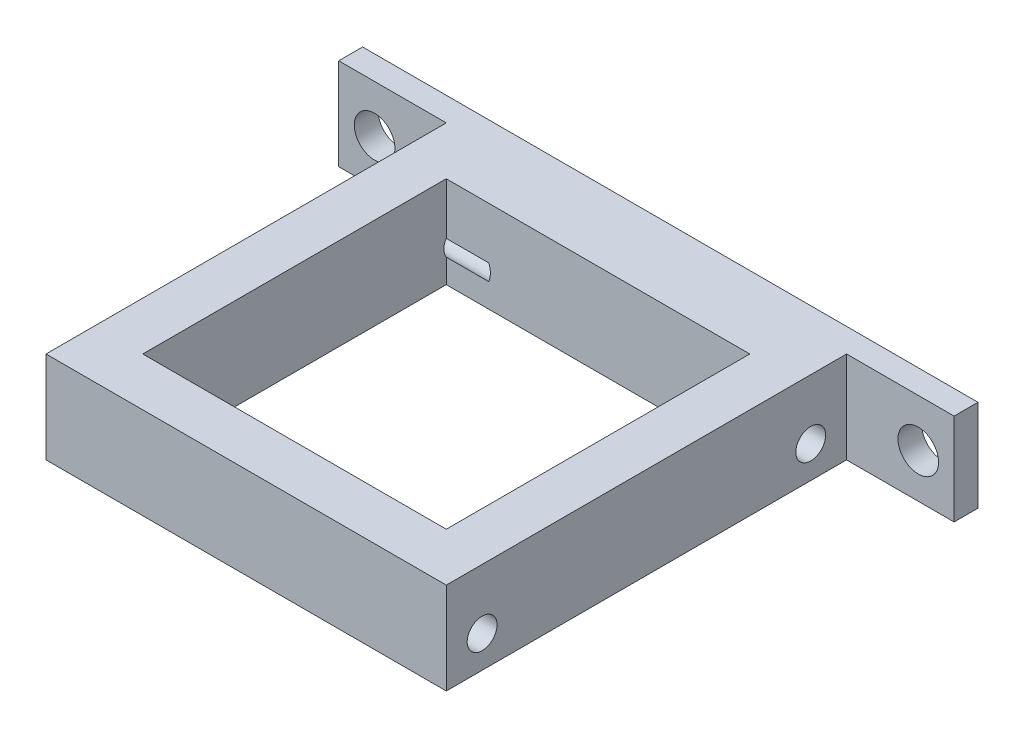
from build123d import *

# Parameters (mm, degrees)
SKETCH1_W                      = 33.5
SKETCH1_H                      = 33.5
BOSS_EXTRUDE1_DEPTH            = 70
M3X0_5_TAPPED_HOLE1_D          = 2.5
M3X0_5_TAPPED_HOLE1_DEPTH      = 7.62
M3X0_5_TAPPED_HOLE1_TIP        = 0.751075774
M3X0_5_TAPPED_HOLE2_D          = 2.5
M3X0_5_TAPPED_HOLE2_DEPTH      = 7.62
M3X0_5_TAPPED_HOLE2_TIP        = 0.751075774
SKETCH7_W                      = 6
SKETCH7_H                      = 50
BOSS_EXTRUDE2_DEPTH            = 3
SKETCH8_W                      = 6
SKETCH8_H                      = 50
BOSS_EXTRUDE3_DEPTH            = 3
SKETCH10_W                     = 1.7
SKETCH10_H                     = 33.5
M3_CLEARANCE_HOLE1_AT_2_COUNT  = 2
M3_CLEARANCE_HOLE1_AT_2_PITCH  = 25
M3_CLEARANCE_HOLE1_AT_3_COUNT  = 2
M3_CLEARANCE_HOLE1_AT_3_PITCH  = 39.5
M3_CLEARANCE_HOLE1_AT_4_COUNT  = 2
M3_CLEARANCE_HOLE1_AT_4_PITCH  = 46.746657635
SKETCH12_W                     = 33.5
SKETCH12_H                     = 45
CUT_EXTRUDE2_DEPTH             = 32.5
M3X0_5_TAPPED_HOLE3_AT_2_COUNT = 2
M3X0_5_TAPPED_HOLE3_AT_2_PITCH = 27.5
SKETCH16_W                     = 45.5
SKETCH16_H                     = 59.85996371
CUT_EXTRUDE3_DEPTH             = 34.5
SKETCH17_W                     = 51.5
SKETCH17_H                     = 11
BOSS_EXTRUDE4_DEPTH            = 2
SKETCH22_W                     = 51.5
SKETCH22_H                     = 3.322905466
CUT_EXTRUDE5_DEPTH             = 36.5
M3_CLEARANCE_HOLE3_D           = 3.4
SKETCH24_W                     = 25.4
SKETCH24_H                     = 25.4
CUT_EXTRUDE6_DEPTH             = 8.677094534


with BuildPart() as part:
    # Sketch1 → Boss-Extrude1 (new body)
    with BuildSketch(Plane(origin=(0, 0, 0), x_dir=(1, 0, 0), z_dir=(0, 1, 0))):
        Rectangle(SKETCH1_W, SKETCH1_H)
    extrude(amount=BOSS_EXTRUDE1_DEPTH)

    # M3x0.5 Tapped Hole1
    with Locations(Plane(origin=(13.75, 70, 13.75), x_dir=(0, 0, 1), z_dir=(0, 1, 0))):
        with Locations((0, 0), (-27.5, -27.5)):
            Hole(M3X0_5_TAPPED_HOLE1_D / 2, depth=M3X0_5_TAPPED_HOLE1_DEPTH)
            with Locations((0, 0, -(M3X0_5_TAPPED_HOLE1_DEPTH + M3X0_5_TAPPED_HOLE1_TIP / 2))):  # 118° drill point
                Cone(0, M3X0_5_TAPPED_HOLE1_D / 2, M3X0_5_TAPPED_HOLE1_TIP, mode=Mode.SUBTRACT)

    # M3x0.5 Tapped Hole2
    with Locations(Plane(origin=(16.75, 6, 13.75), x_dir=(0, 0, 1), z_dir=(1, 0, 0))):
        with Locations((0, 0), (-27.5, 0)):
            Hole(M3X0_5_TAPPED_HOLE2_D / 2, depth=M3X0_5_TAPPED_HOLE2_DEPTH)
            with Locations((0, 0, -(M3X0_5_TAPPED_HOLE2_DEPTH + M3X0_5_TAPPED_HOLE2_TIP / 2))):  # 118° drill point
                Cone(0, M3X0_5_TAPPED_HOLE2_D / 2, M3X0_5_TAPPED_HOLE2_TIP, mode=Mode.SUBTRACT)

    # Sketch12 → Cut-Extrude2 (cut)
    with BuildSketch(Plane.XY.offset(16.75)):
        with Locations((0, 35.5)):
            Rectangle(SKETCH12_W, SKETCH12_H)
    extrude(amount=-CUT_EXTRUDE2_DEPTH, mode=Mode.SUBTRACT)

    # Sketch13 → M3x0.5 Tapped Hole3 (revolve, cut)
    with BuildSketch(Plane(origin=(-16.75, 6, -13.75), x_dir=(0, 0, 1), z_dir=(0, 1, 0))):
        Polygon((0, 0), (0, 8.371075774), (1.25, 7.62), (1.25, 0), align=None)
    m3x0_5_tapped_hole3 = revolve(axis=Axis((-23.1, 6, -13.75), (1, 0, 0)), mode=Mode.SUBTRACT)

    # M3x0.5 Tapped Hole3 at 2: M3x0.5 Tapped Hole3 ×2
    with Locations(*[(0, 0, i * M3X0_5_TAPPED_HOLE3_AT_2_PITCH) for i in range(1, M3X0_5_TAPPED_HOLE3_AT_2_COUNT)]):
        add(m3x0_5_tapped_hole3, mode=Mode.SUBTRACT)


with BuildPart() as body_2:
    # Sketch7 → Boss-Extrude2 (new body)
    with BuildSketch(Plane(origin=(0, 0, -16.75), x_dir=(-1, 0, 0), z_dir=(0, 0, -1))):
        with Locations((-19.75, 36)):
            Rectangle(SKETCH7_W, SKETCH7_H)
    extrude(amount=-BOSS_EXTRUDE2_DEPTH)

    # Sketch10 → M3 Clearance Hole1 (revolve, cut)
    with BuildSketch(Plane(origin=(19.75, 51, -16.75), x_dir=(0, 1, 0), z_dir=(1, 0, 0))):
        with Locations((0.85, 16.75)):
            Rectangle(SKETCH10_W, SKETCH10_H)
    m3_clearance_hole1 = revolve(axis=Axis((19.75, 51, -23.1), (0, 0, 1)), mode=Mode.SUBTRACT)

    # M3 Clearance Hole1 at 2: M3 Clearance Hole1 ×2
    with Locations(*[(0, -i * M3_CLEARANCE_HOLE1_AT_2_PITCH, 0) for i in range(1, M3_CLEARANCE_HOLE1_AT_2_COUNT)]):
        add(m3_clearance_hole1, mode=Mode.SUBTRACT)


with BuildPart() as body_3:
    # Sketch8 → Boss-Extrude3 (new body)
    with BuildSketch(Plane(origin=(0, 0, -16.75), x_dir=(-1, 0, 0), z_dir=(0, 0, -1))):
        with Locations((19.75, 36)):
            Rectangle(SKETCH8_W, SKETCH8_H)
    extrude(amount=-BOSS_EXTRUDE3_DEPTH)

    # M3 Clearance Hole1 at 3: M3 Clearance Hole1 ×2
    with Locations(*[(-i * M3_CLEARANCE_HOLE1_AT_3_PITCH, 0, 0) for i in range(1, M3_CLEARANCE_HOLE1_AT_3_COUNT)]):
        add(m3_clearance_hole1, mode=Mode.SUBTRACT)

    # M3 Clearance Hole1 at 4: M3 Clearance Hole1 ×2
    with Locations(*[Vector(-0.844980197, -0.534797593, 0) * (i * M3_CLEARANCE_HOLE1_AT_4_PITCH) for i in range(1, M3_CLEARANCE_HOLE1_AT_4_COUNT)]):
        add(m3_clearance_hole1, mode=Mode.SUBTRACT)


with BuildPart() as cut_extrude3_tool:
    # Sketch16 → Cut-Extrude3 (new body, through all)
    with BuildSketch(Plane.XY.offset(16.75)):
        with Locations((0, 40.929981855)):
            Rectangle(SKETCH16_W, SKETCH16_H)
    extrude(amount=-CUT_EXTRUDE3_DEPTH)


with BuildPart() as part_1:
    add(part.part)

    # Cut-Extrude3: cut by cut_extrude3_tool
    add(cut_extrude3_tool.part, mode=Mode.SUBTRACT)

    # Sketch17 → Boss-Extrude4 (add)
    with BuildSketch(Plane(origin=(0, 0, -16.75), x_dir=(-1, 0, 0), z_dir=(0, 0, -1))):
        with Locations((0, 5.5)):
            Rectangle(SKETCH17_W, SKETCH17_H)
    extrude(amount=BOSS_EXTRUDE4_DEPTH)

    # Sketch22 → Cut-Extrude5 (cut, through all)
    with BuildSketch(Plane(origin=(0, 0, -18.75), x_dir=(-1, 0, 0), z_dir=(0, 0, -1))):
        with Locations((0, 1.661452733)):
            Rectangle(SKETCH22_W, SKETCH22_H)
    extrude(amount=-CUT_EXTRUDE5_DEPTH, mode=Mode.SUBTRACT)

    # M3 Clearance Hole3 (through all)
    with Locations(Plane(origin=(22.75, 7, -16.75), x_dir=(1, 0, 0), z_dir=(0, 0, 1))):
        with Locations((0, 0), (-45.5, 0)):
            Hole(M3_CLEARANCE_HOLE3_D / 2)

    # Sketch24 → Cut-Extrude6 (cut, through all)
    with BuildSketch(Plane(origin=(0, 11, 0), x_dir=(1, 0, 0), z_dir=(0, 1, 0))):
        Rectangle(SKETCH24_W, SKETCH24_H)
    extrude(amount=-CUT_EXTRUDE6_DEPTH, mode=Mode.SUBTRACT)


with BuildPart() as body_2_1:
    add(body_2.part)

    # Cut-Extrude3: cut by cut_extrude3_tool
    add(cut_extrude3_tool.part, mode=Mode.SUBTRACT)


with BuildPart() as body_3_1:
    add(body_3.part)

    # Cut-Extrude3: cut by cut_extrude3_tool
    add(cut_extrude3_tool.part, mode=Mode.SUBTRACT)


solid = part_1.part
